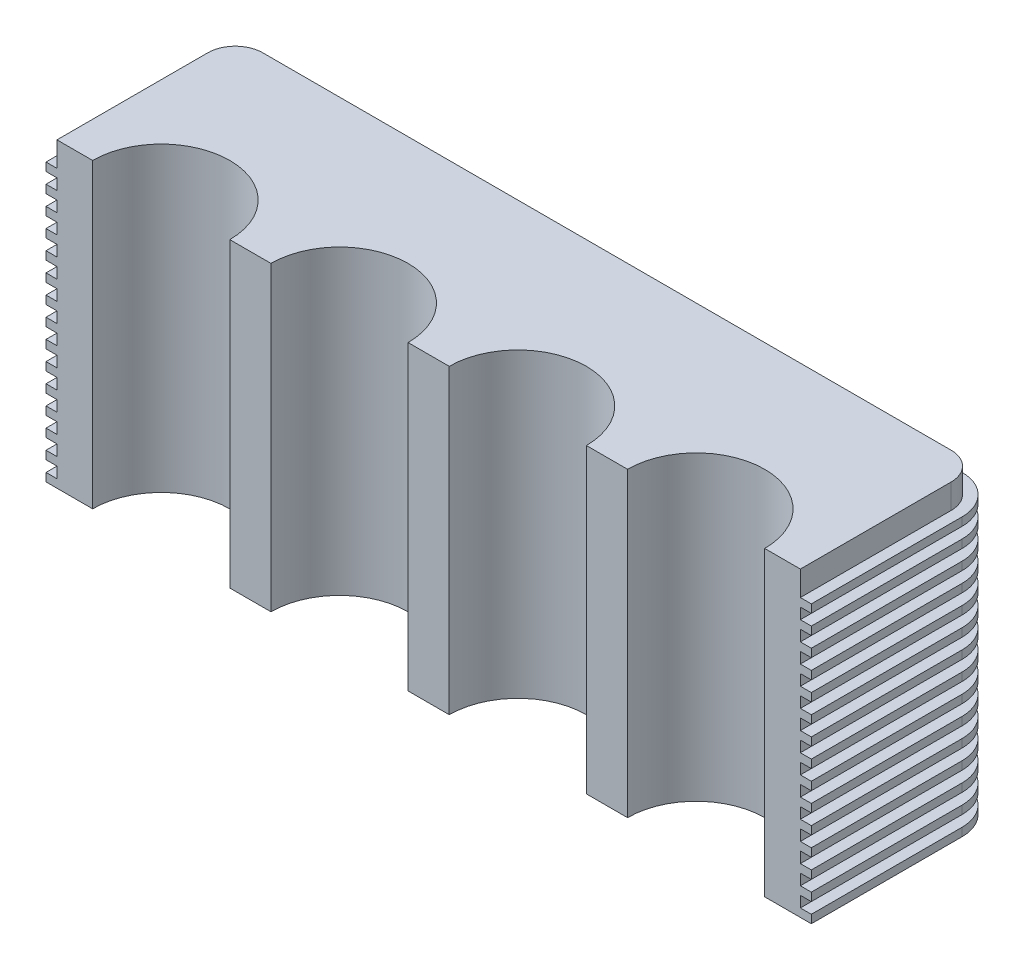
from build123d import *

# Parameters (mm, degrees)
BOSS_EXTRUDE1_DEPTH = 110
BOSS_EXTRUDE2_DEPTH = 3
LPATTERN1_COUNT     = 15
LPATTERN1_PITCH     = 7


with BuildPart() as part:
    # Sketch1 → Boss-Extrude1 (new body)
    with BuildSketch(Plane(origin=(0, 0, 0), x_dir=(1, 0, 0), z_dir=(0, 1, 0))):
        with BuildLine():
            Line((0, 0), (13, 0))
            ThreePointArc((13, 0), (38, 25), (63, 0))
            Line((63, 0), (78, 0))
            ThreePointArc((78, 0), (103, 25), (128, 0))
            Line((128, 0), (143, 0))
            ThreePointArc((143, 0), (168, 25), (193, 0))
            Line((193, 0), (208, 0))
            ThreePointArc((208, 0), (233, 25), (258, 0))
            Line((258, 0), (271, 0))
            Line((271, 0), (271, 55))
            ThreePointArc((271, 55), (268.071067812, 62.071067812), (261, 65))
            Line((261, 65), (10, 65))
            ThreePointArc((10, 65), (2.928932188, 62.071067812), (0, 55))
            Line((0, 55), (0, 0))
        make_face()
    extrude(amount=BOSS_EXTRUDE1_DEPTH)

    # Sketch4 → Boss-Extrude2 (add)
    with BuildSketch(Plane(origin=(0, 0, 0), x_dir=(1, 0, 0), z_dir=(0, 1, 0))):
        with BuildLine():
            Line((275, 0), (275, 55))
            ThreePointArc((275, 55), (270.899494937, 64.899494937), (261, 69))
            Line((261, 69), (10, 69))
            ThreePointArc((10, 69), (0.100505063, 64.899494937), (-4, 55))
            Line((-4, 55), (-4, 0))
            Line((-4, 0), (0, 0))
            Line((0, 0), (0, 55))
            ThreePointArc((0, 55), (2.928932188, 62.071067812), (10, 65))
            Line((10, 65), (261, 65))
            ThreePointArc((261, 65), (268.071067812, 62.071067812), (271, 55))
            Line((271, 55), (271, 0))
            Line((271, 0), (275, 0))
        make_face()
    boss_extrude2 = extrude(amount=BOSS_EXTRUDE2_DEPTH)

    # LPattern1: Boss-Extrude2 ×15
    with Locations(*[(0, i * LPATTERN1_PITCH, 0) for i in range(1, LPATTERN1_COUNT)]):
        add(boss_extrude2)


solid = part.part
